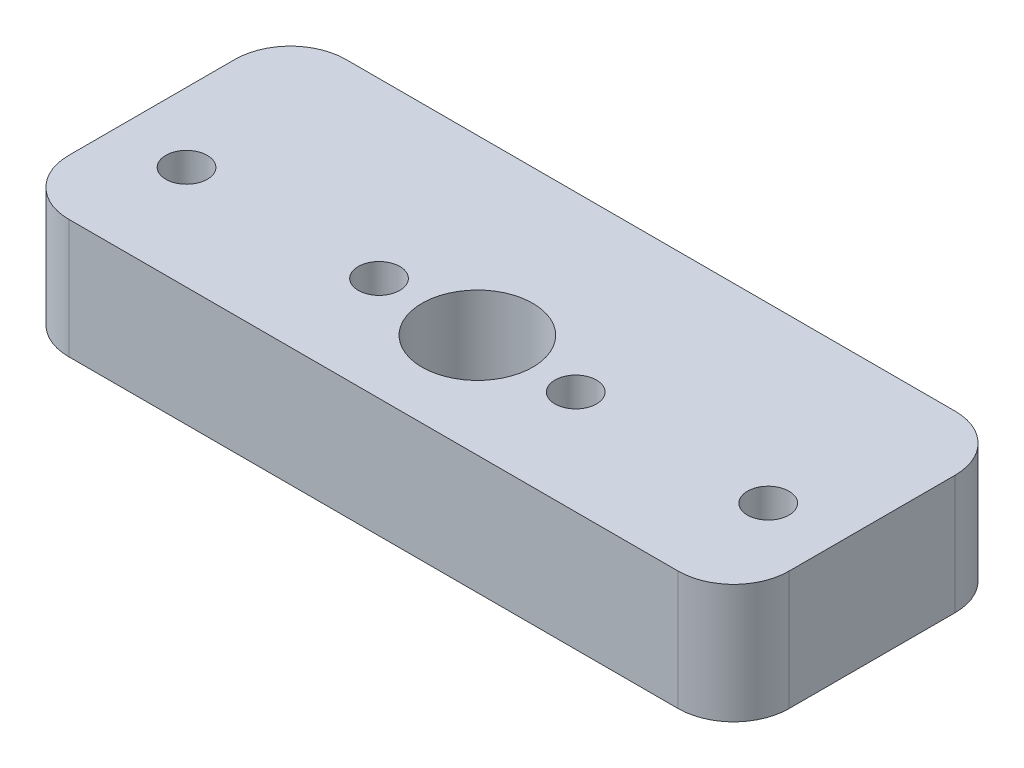
from build123d import *

# Parameters (mm, degrees)
SKETCH1_R           = 4
SKETCH1_R_2         = 1.5
BOSS_EXTRUDE1_DEPTH = 8.6


with BuildPart() as part:
    # Sketch1 → Boss-Extrude1 (new body)
    with BuildSketch(Plane(origin=(0, 0, 0), x_dir=(1, 0, 0), z_dir=(0, 1, 0))):
        with BuildLine():
            Line((-22, 10), (22, 10))
            ThreePointArc((22, 10), (24.828427125, 8.828427125), (26, 6))
            Line((26, 6), (26, -6))
            ThreePointArc((26, -6), (24.828427125, -8.828427125), (22, -10))
            Line((22, -10), (-22, -10))
            ThreePointArc((-22, -10), (-24.828427125, -8.828427125), (-26, -6))
            Line((-26, -6), (-26, 6))
            ThreePointArc((-26, 6), (-24.828427125, 8.828427125), (-22, 10))
        make_face()
        with Locations((0, -2.5)):
            Circle(SKETCH1_R, mode=Mode.SUBTRACT)
        with Locations((7.1, -2.5)):
            Circle(SKETCH1_R_2, mode=Mode.SUBTRACT)
        with Locations((21, -2.5)):
            Circle(SKETCH1_R_2, mode=Mode.SUBTRACT)
        with Locations((-21, -2.5)):
            Circle(SKETCH1_R_2, mode=Mode.SUBTRACT)
        with Locations((-7.1, -2.5)):
            Circle(SKETCH1_R_2, mode=Mode.SUBTRACT)
    extrude(amount=BOSS_EXTRUDE1_DEPTH)


solid = part.part
